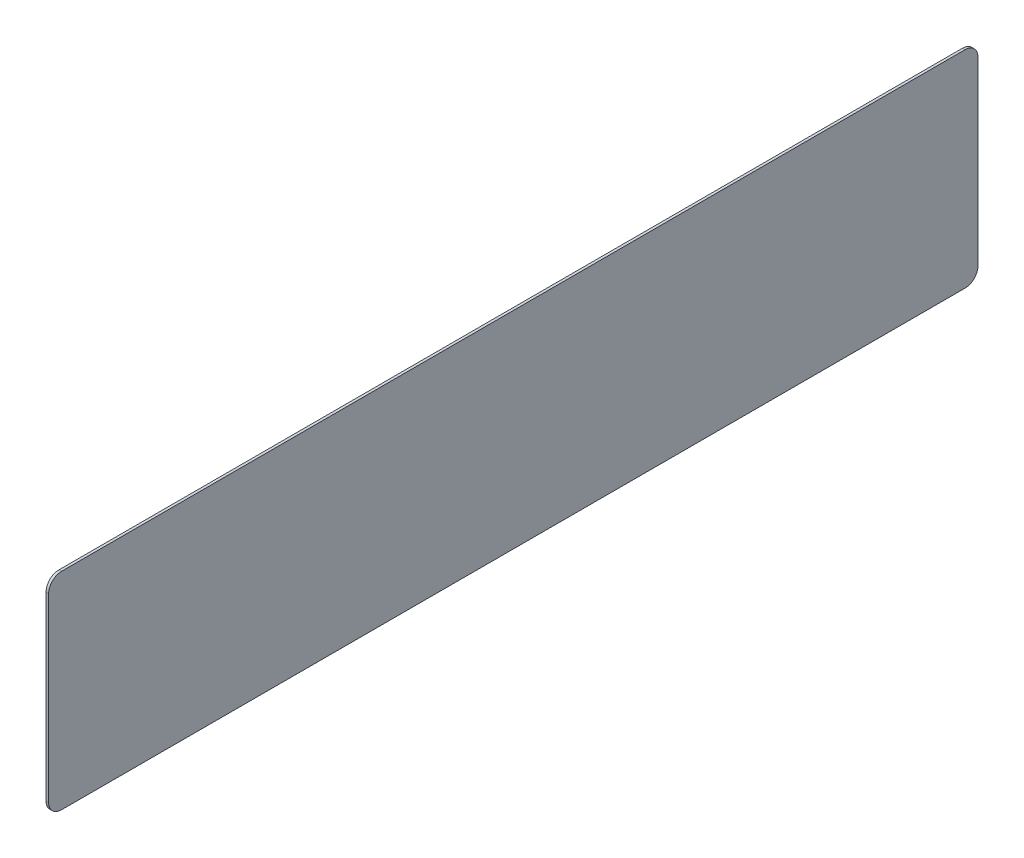
from build123d import *

# Parameters (mm, degrees)
SKETCH1_W           = 180
SKETCH1_H           = 40
BOSS_EXTRUDE1_DEPTH = 0.5
FILLET1_R           = 2.5


with BuildPart() as part:
    # Sketch1 → Boss-Extrude1 (new body)
    with BuildSketch(Plane(origin=(0, 0, 0), x_dir=(0, 0, -1), z_dir=(1, 0, 0))):
        Rectangle(SKETCH1_W, SKETCH1_H)
    extrude(amount=BOSS_EXTRUDE1_DEPTH)

    # Fillet1
    fillet1_edges = [part.edges().sort_by_distance(p)[0] for p in [
        (0.25, -20, -90),
        (0.25, -20, 90),
        (0.25, 20, 90),
        (0.25, 20, -90),
    ]]
    fillet(fillet1_edges, radius=FILLET1_R)


solid = part.part
